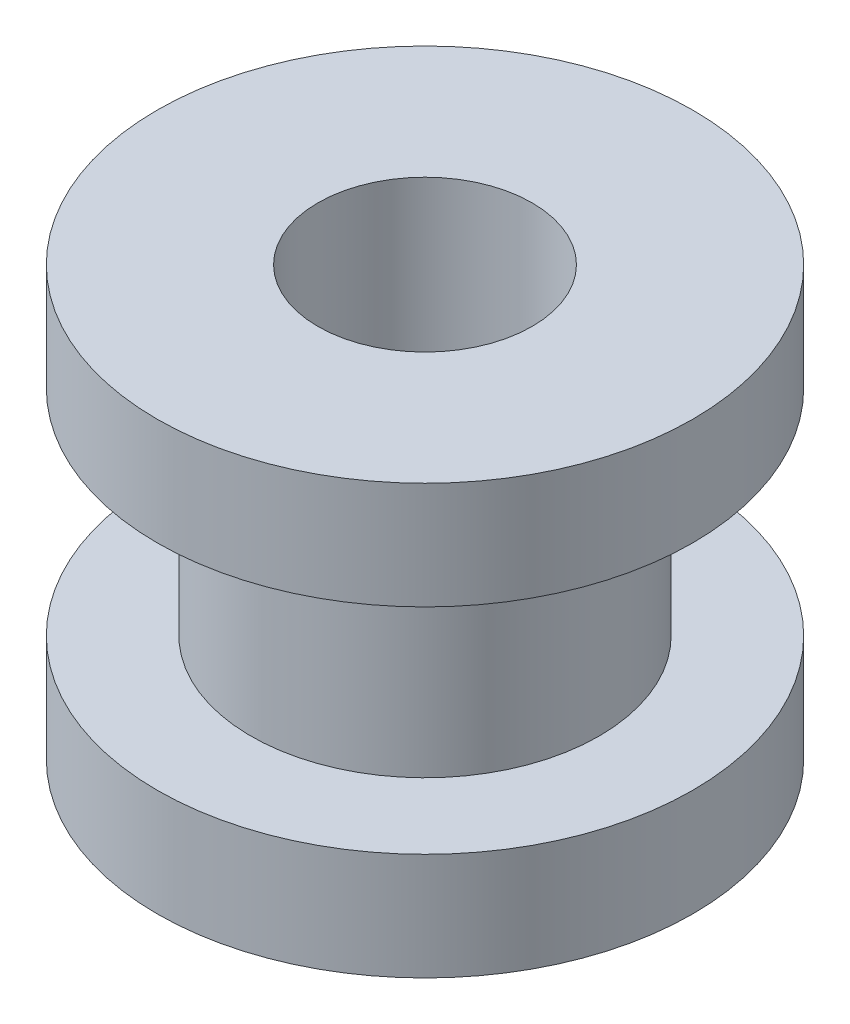
from build123d import *


with BuildPart() as part:
    # Sketch2 → Revolve1 (revolve)
    with BuildSketch(Plane.XY):
        Polygon((2, 4), (2, -4), (5, -4), (5, -2), (3.25, -2), (3.25, 2), (5, 2), (5, 4), align=None)
    revolve(axis=Axis((0, -211.476359703, 0), (0, 1, 0)))


solid = part.part
